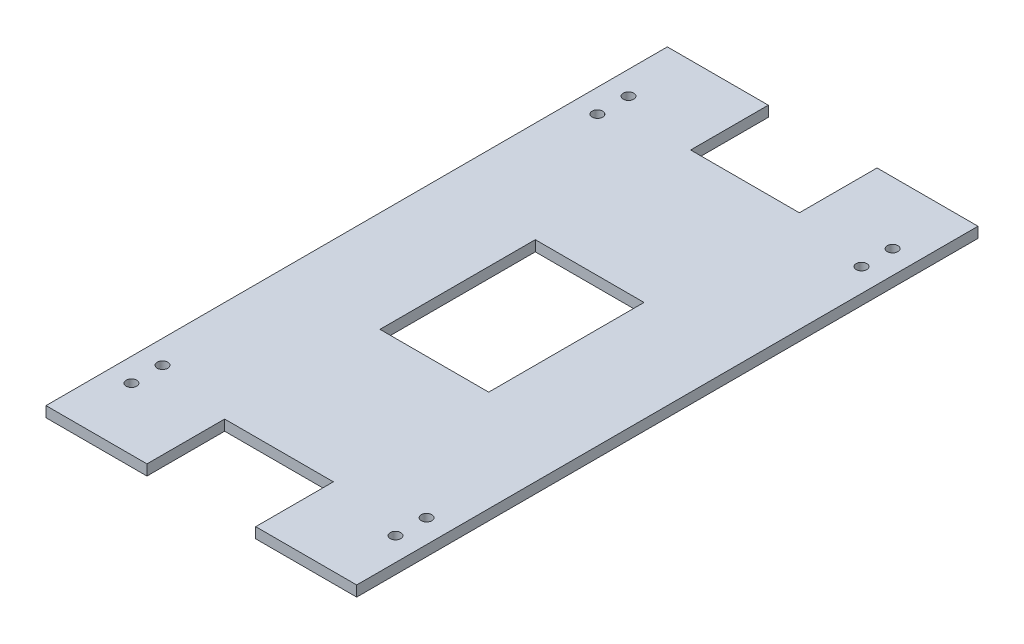
from build123d import *

# Parameters (mm, degrees)
CROQUIS1_W              = 100
CROQUIS1_H              = 200
SALIENTE_EXTRUIR1_DEPTH = 3.4
CROQUIS2_R              = 1.7
CROQUIS2_W              = 35
CROQUIS2_H              = 25
CROQUIS2_H_2            = 50
CORTAR_EXTRUIR1_DEPTH   = 3.4


with BuildPart() as part:
    # Croquis1 → Saliente-Extruir1 (new body)
    with BuildSketch(Plane(origin=(0, 0, 0), x_dir=(1, 0, 0), z_dir=(0, 1, 0))):
        Rectangle(CROQUIS1_W, CROQUIS1_H)
    extrude(amount=SALIENTE_EXTRUIR1_DEPTH)

    # Croquis2 → Cortar-Extruir1 (cut)
    with BuildSketch(Plane(origin=(0, 3.4, 0), x_dir=(1, 0, 0), z_dir=(0, 1, 0))):
        with Locations((42.5, -80)):
            Circle(CROQUIS2_R)
        with Locations((42.5, -70)):
            Circle(CROQUIS2_R)
        with Locations((-42.5, -80)):
            Circle(CROQUIS2_R)
        with Locations((-42.5, -70)):
            Circle(CROQUIS2_R)
        with Locations((42.5, 70)):
            Circle(CROQUIS2_R)
        with Locations((42.5, 80)):
            Circle(CROQUIS2_R)
        with Locations((-42.5, 70)):
            Circle(CROQUIS2_R)
        with Locations((-42.5, 80)):
            Circle(CROQUIS2_R)
        with Locations((0, 87.5)):
            Rectangle(CROQUIS2_W, CROQUIS2_H)
        Rectangle(CROQUIS2_W, CROQUIS2_H_2)
        with Locations((0, -87.5)):
            Rectangle(CROQUIS2_W, CROQUIS2_H)
    extrude(amount=-CORTAR_EXTRUIR1_DEPTH, mode=Mode.SUBTRACT)


solid = part.part
